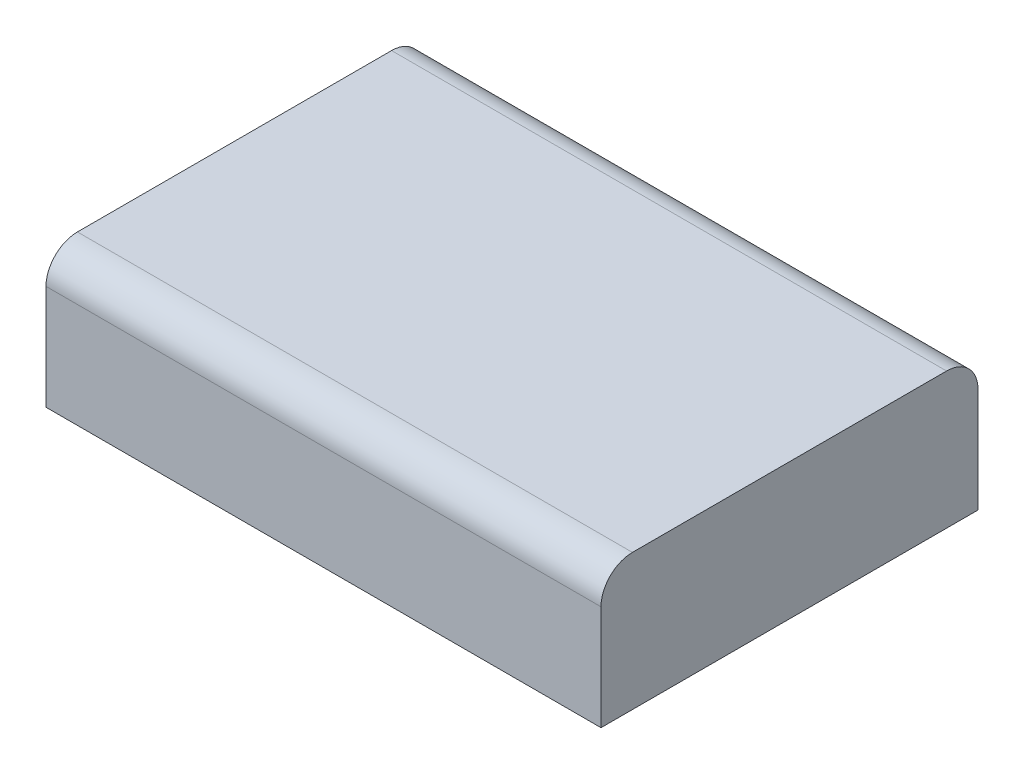
from build123d import *

# Parameters (mm, degrees)
SKETCH1_W           = 53
SKETCH1_H           = 36
BOSS_EXTRUDE1_DEPTH = 13
CUT_EXTRUDE1_DEPTH  = 54


with BuildPart() as part:
    # Sketch1 → Boss-Extrude1 (new body)
    with BuildSketch(Plane(origin=(0, 0, 0), x_dir=(1, 0, 0), z_dir=(0, 1, 0))):
        Rectangle(SKETCH1_W, SKETCH1_H)
    extrude(amount=BOSS_EXTRUDE1_DEPTH)

    # Sketch2 → Cut-Extrude1 (cut, through all)
    with BuildSketch(Plane(origin=(26.5, 0, 0), x_dir=(0, 0, -1), z_dir=(1, 0, 0))):
        with BuildLine():
            Line((-18, 13), (-15, 13))
            ThreePointArc((-15, 13), (-17.121320344, 12.121320344), (-18, 10))
            Line((-18, 10), (-18, 13))
        make_face()
        with BuildLine():
            Line((15, 13), (18, 13))
            Line((18, 13), (18, 10))
            ThreePointArc((18, 10), (17.121320344, 12.121320344), (15, 13))
        make_face()
    extrude(amount=-CUT_EXTRUDE1_DEPTH, mode=Mode.SUBTRACT)


solid = part.part
